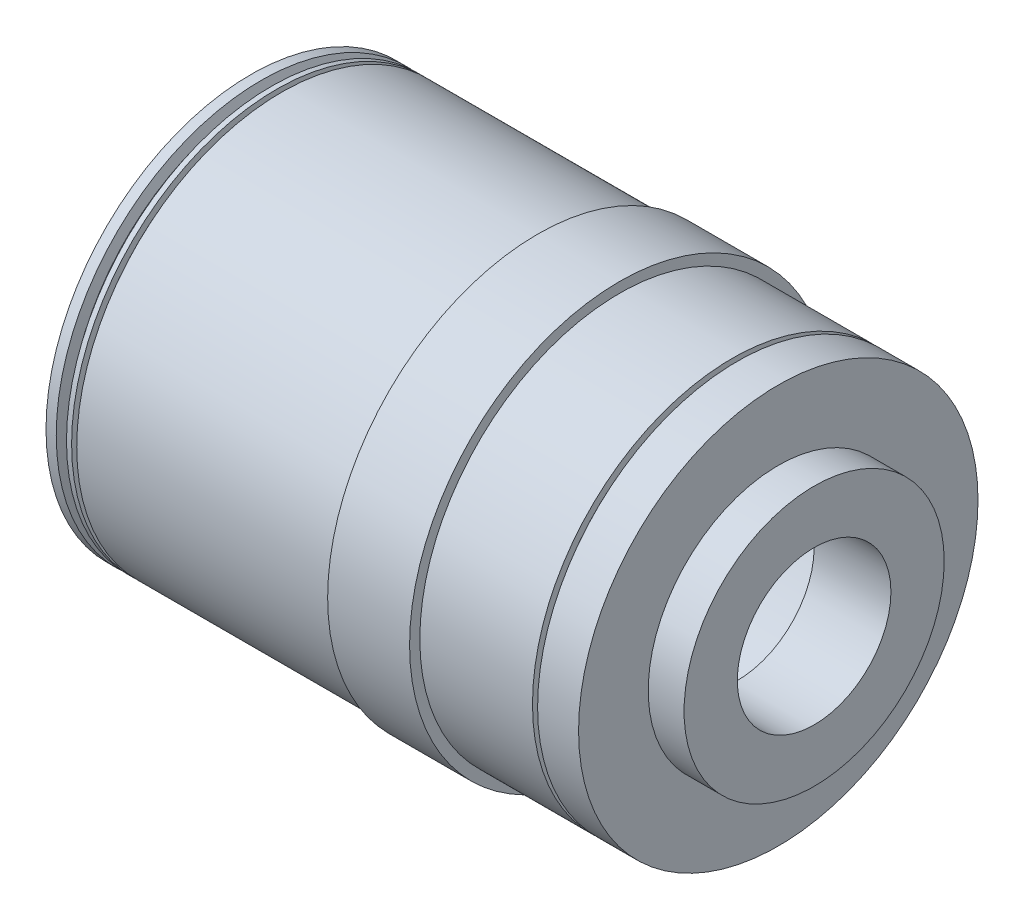
from build123d import *

# Parameters (mm, degrees)
SKETCH1_R           = 19.5
SKETCH1_R_2         = 7.5
BOSS_EXTRUDE1_DEPTH = 4
BOSS_EXTRUDE2_START = 11.5
SKETCH2_R           = 19.5
SKETCH2_R_2         = 17
BOSS_EXTRUDE2_DEPTH = 11.5
SKETCH3_W           = 0.5
SKETCH3_H           = 0.7
BOSS_EXTRUDE3_START = 8
SKETCH4_R           = 20.5
SKETCH4_R_2         = 17
BOSS_EXTRUDE3_DEPTH = 8
BOSS_EXTRUDE4_START = 28
SKETCH5_R           = 20
SKETCH5_R_2         = 17
BOSS_EXTRUDE4_DEPTH = 28
SKETCH6_W           = 0.5
SKETCH6_H           = 0.7
SKETCH7_R           = 12.7
SKETCH7_R_2         = 7.5
BOSS_EXTRUDE5_DEPTH = 3.5
SKETCH8_R           = 20.5
SKETCH8_R_2         = 3
BOSS_EXTRUDE6_DEPTH = 5


with BuildPart() as part:
    # Sketch1 → Boss-Extrude1 (new body)
    with BuildSketch(Plane(origin=(0, 0, 0), x_dir=(0, 0, -1), z_dir=(1, 0, 0))):
        Circle(SKETCH1_R)
        Circle(SKETCH1_R_2, mode=Mode.SUBTRACT)
    extrude(amount=BOSS_EXTRUDE1_DEPTH)

    # Sketch2 → Boss-Extrude2 (add)
    with BuildSketch(Plane.ZY.offset(BOSS_EXTRUDE2_START)):
        Circle(SKETCH2_R)
        Circle(SKETCH2_R_2, mode=Mode.SUBTRACT)
    extrude(amount=-BOSS_EXTRUDE2_DEPTH)

    # Sketch3 → Cut-Revolve1 (revolve, cut)
    with BuildSketch(Plane.XY):
        with Locations((-0.25, 19.15)):
            Rectangle(SKETCH3_W, SKETCH3_H)
    revolve(axis=Axis((-11.5, 0, 0), (1, 0, 0)), mode=Mode.SUBTRACT)

    # Sketch4 → Boss-Extrude3 (add)
    with BuildSketch(Plane.ZY.offset(11.5).offset(BOSS_EXTRUDE3_START)):
        Circle(SKETCH4_R)
        Circle(SKETCH4_R_2, mode=Mode.SUBTRACT)
    extrude(amount=-BOSS_EXTRUDE3_DEPTH)

    # Sketch5 → Boss-Extrude4 (add)
    with BuildSketch(Plane.ZY.offset(19.5).offset(BOSS_EXTRUDE4_START)):
        Circle(SKETCH5_R)
        Circle(SKETCH5_R_2, mode=Mode.SUBTRACT)
    extrude(amount=-BOSS_EXTRUDE4_DEPTH)

    # Sketch6 → Cut-Revolve2 (revolve, cut)
    with BuildSketch(Plane.XY):
        with Locations((-44.75, 19.65)):
            Rectangle(SKETCH6_W, SKETCH6_H)
        Polygon((-45.5, 20), (-46.5, 20), (-46.15, 19.15), (-45.85, 19.15), align=None)
    revolve(axis=Axis((-11.5, 0, 0), (1, 0, 0)), mode=Mode.SUBTRACT)

    # Sketch7 → Boss-Extrude5 (add)
    with BuildSketch(Plane(origin=(4, 0, 0), x_dir=(0, 0, -1), z_dir=(1, 0, 0))):
        Circle(SKETCH7_R)
        Circle(SKETCH7_R_2, mode=Mode.SUBTRACT)
    extrude(amount=BOSS_EXTRUDE5_DEPTH)

    # Sketch8 → Boss-Extrude6 (add)
    with BuildSketch(Plane.ZY.offset(19.5)):
        Circle(SKETCH8_R)
        Circle(SKETCH8_R_2, mode=Mode.SUBTRACT)
    extrude(amount=-BOSS_EXTRUDE6_DEPTH)


solid = part.part
